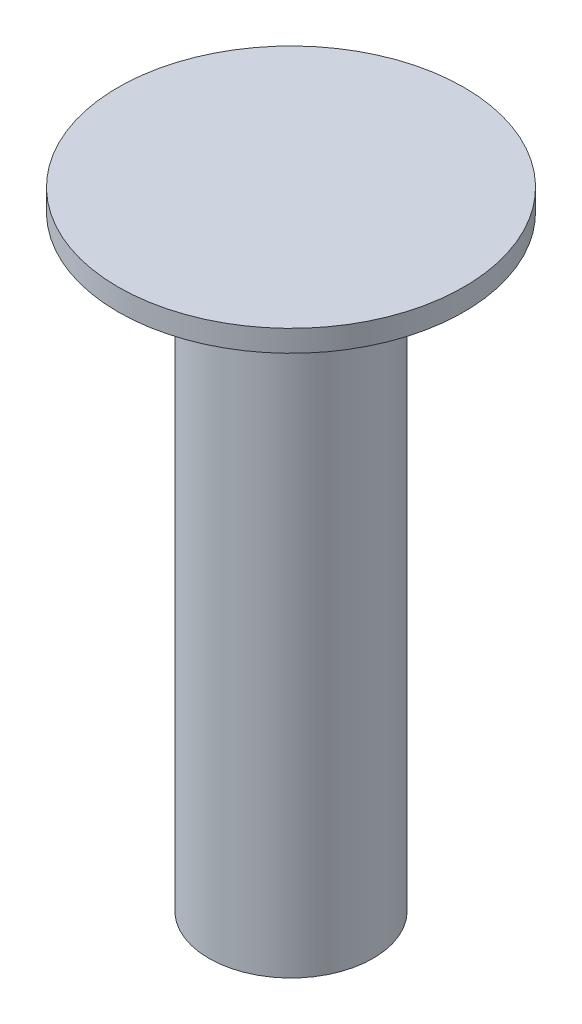
from build123d import *

# Parameters (mm, degrees)
CROQUIS1_R              = 3.8
SALIENTE_EXTRUIR1_DEPTH = 14
CROQUIS2_R              = 8
SALIENTE_EXTRUIR2_DEPTH = 1


with BuildPart() as part:
    # Croquis1 → Saliente-Extruir1 (new body, symmetric)
    with BuildSketch(Plane(origin=(0, 0, 0), x_dir=(1, 0, 0), z_dir=(0, 1, 0))):
        Circle(CROQUIS1_R)
    extrude(amount=SALIENTE_EXTRUIR1_DEPTH, both=True)

    # Croquis2 → Saliente-Extruir2 (add)
    with BuildSketch(Plane(origin=(0, 14, 0), x_dir=(1, 0, 0), z_dir=(0, 1, 0))):
        Circle(CROQUIS2_R)
    extrude(amount=SALIENTE_EXTRUIR2_DEPTH)


solid = part.part
